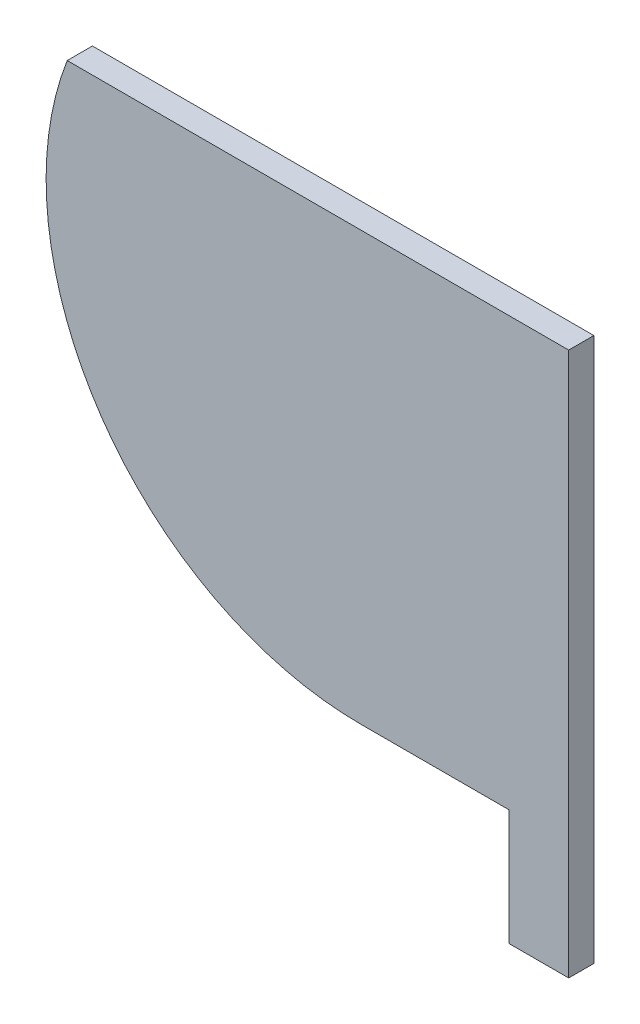
from build123d import *

# Parameters (mm, degrees)
BOSS_EXTRUDE1_DEPTH = 5
SKETCH2_W           = 11.880182207
SKETCH2_H           = 23
BOSS_EXTRUDE2_DEPTH = 5


with BuildPart() as part:
    # Sketch1 → Boss-Extrude1 (new body)
    with BuildSketch(Plane.XY):
        with BuildLine():
            Line((0, 0), (0, -85))
            Line((0, -85), (-41.280574715, -85))
            ThreePointArc((-41.280574715, -85), (-92.819395035, -57.855339059), (-99.590093663, 0))
            Line((-99.590093663, 0), (0, 0))
        make_face()
    extrude(amount=BOSS_EXTRUDE1_DEPTH)

    # Sketch2 → Boss-Extrude2 (add)
    with BuildSketch(Plane.XY.offset(5)):
        with Locations((-5.940091104, -96.5)):
            Rectangle(SKETCH2_W, SKETCH2_H)
    extrude(amount=-BOSS_EXTRUDE2_DEPTH)


solid = part.part
